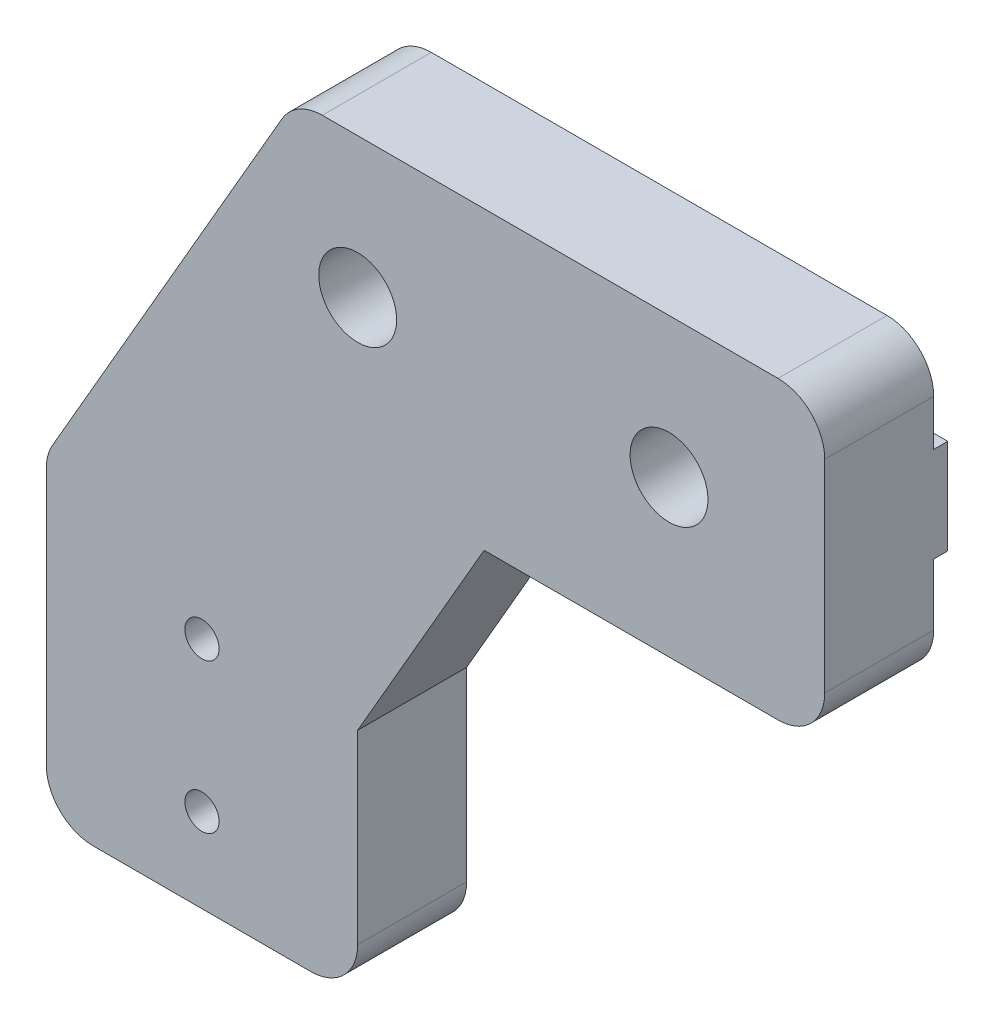
from build123d import *

# Parameters (mm, degrees)
SKETCH1_R           = 2.5
SKETCH1_R_2         = 1.1
BOSS_EXTRUDE1_DEPTH = 7
BOSS_EXTRUDE2_REACH = 52
SKETCH2_W           = 0.9
SKETCH2_H           = 6.1
CUT_EXTRUDE1_REACH  = 2.9
SKETCH3_R           = 2.5


with BuildPart() as part:
    # Sketch1 → Boss-Extrude1 (new body)
    with BuildSketch(Plane.XY):
        with BuildLine():
            Line((3, 0), (17, 0))
            ThreePointArc((17, 0), (19.121320344, 0.878679656), (20, 3))
            Line((20, 3), (20, 14.92820323))
            Line((20, 14.92820323), (28.124355653, 29))
            Line((28.124355653, 29), (47, 29))
            ThreePointArc((47, 29), (49.121320344, 29.878679656), (50, 32))
            Line((50, 32), (50, 45))
            ThreePointArc((50, 45), (49.121320344, 47.121320344), (47, 48))
            Line((47, 48), (17.732050808, 48))
            ThreePointArc((17.732050808, 48), (16.232050808, 47.598076211), (15.133974596, 46.5))
            Line((15.133974596, 46.5), (0.401923789, 20.983339502))
            ThreePointArc((0.401923789, 20.983339502), (0.102222521, 20.259796637), (0, 19.483339502))
            Line((0, 19.483339502), (0, 3))
            ThreePointArc((0, 3), (0.878679656, 0.878679656), (3, 0))
        make_face()
        with Locations((20, 39)):
            Circle(SKETCH1_R, mode=Mode.SUBTRACT)
        with Locations((40, 39)):
            Circle(SKETCH1_R, mode=Mode.SUBTRACT)
        with Locations((10, 5.4)):
            Circle(SKETCH1_R_2, mode=Mode.SUBTRACT)
        with Locations((10, 15)):
            Circle(SKETCH1_R_2, mode=Mode.SUBTRACT)
    extrude(amount=BOSS_EXTRUDE1_DEPTH)

    # Boss-Extrude2: up to this face of the body (flat: up to its plane)
    boss_extrude2_end = Plane(part.part.faces().sort_by_distance((7.767949192, 33.741669751, 3.5))[0])
    # Sketch2 → Boss-Extrude2 (add, up to the picked face)
    with BuildSketch(Plane(origin=(50, 0, 0), x_dir=(0, 0, -1), z_dir=(1, 0, 0)), mode=Mode.PRIVATE) as boss_extrude2_sk1:
        with Locations((0.45, 39)):
            Rectangle(SKETCH2_W, SKETCH2_H)
    boss_extrude2_tool1 = split(extrude(boss_extrude2_sk1.sketch, amount=-BOSS_EXTRUDE2_REACH, mode=Mode.PRIVATE), bisect_by=boss_extrude2_end, keep=Keep.BOTH, mode=Mode.PRIVATE)
    add(boss_extrude2_tool1.solids().sort_by_distance((50, 39, -0.45))[0])

    # Sketch3 → Cut-Extrude1 (cut, up to next)
    with BuildSketch(Plane.XY, mode=Mode.PRIVATE) as cut_extrude1_sk1:
        with Locations((20, 39)):
            Circle(SKETCH3_R)
    cut_extrude1_tool1 = extrude(cut_extrude1_sk1.sketch, amount=-CUT_EXTRUDE1_REACH, mode=Mode.PRIVATE) & part.part
    add(cut_extrude1_tool1.solids().sort_by_distance((20, 39, 0))[0], mode=Mode.SUBTRACT)
    # Sketch3 → Cut-Extrude1 (cut, up to next)
    with BuildSketch(Plane.XY, mode=Mode.PRIVATE) as cut_extrude1_sk2:
        with Locations((40, 39)):
            Circle(SKETCH3_R)
    cut_extrude1_tool2 = extrude(cut_extrude1_sk2.sketch, amount=-CUT_EXTRUDE1_REACH, mode=Mode.PRIVATE) & part.part
    add(cut_extrude1_tool2.solids().sort_by_distance((40, 39, 0))[0], mode=Mode.SUBTRACT)


solid = part.part
